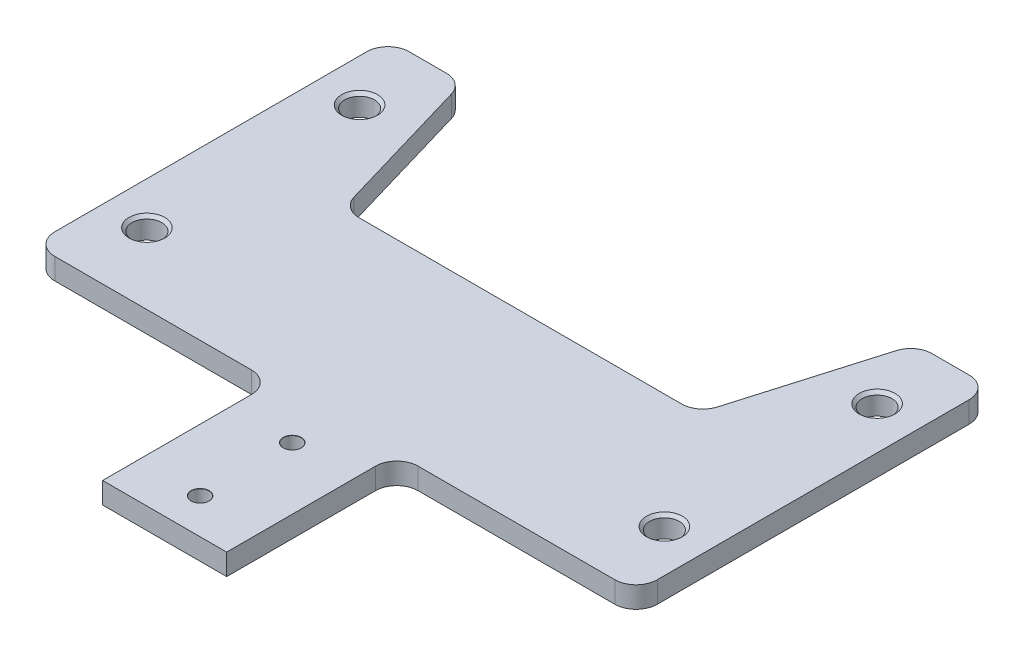
from build123d import *

# Parameters (mm, degrees)
BOSS_EXTRUDE1_DEPTH                  = 3
SKETCH10_W                           = 17.5
SKETCH10_H                           = 24
BOSS_EXTRUDE2_DEPTH                  = 3
F_2_5_2_5_DIAMETER_HOLE1_D           = 2.5
F_2_5_2_5_DIAMETER_HOLE1_DEPTH       = 6.35
F_2_5_2_5_DIAMETER_HOLE1_CSINK_D     = 2.55
F_2_5_2_5_DIAMETER_HOLE1_CSINK_ANGLE = 90
F_2_5_2_5_DIAMETER_HOLE1_TIP         = 0.751075774
M5X0_8_TAPPED_HOLE1_D                = 4.2
M5X0_8_TAPPED_HOLE1_DEPTH            = 12.4
M5X0_8_TAPPED_HOLE1_CSINK_D          = 5.05
M5X0_8_TAPPED_HOLE1_CSINK_ANGLE      = 90
M5X0_8_TAPPED_HOLE1_TIP              = 1.2618073
CUT_EXTRUDE3_DEPTH                   = 4
FILLET1_R                            = 3


with BuildPart() as part:
    # Sketch2 → Boss-Extrude1 (new body)
    with BuildSketch(Plane(origin=(0, 0, 0), x_dir=(1, 0, 0), z_dir=(0, 1, 0))):
        Polygon((42.5, 0), (42.5, 50), (22.5, 50), (8.75, 26.184301396), (-8.75, 26.184301396), (-22.5, 50), (-42.5, 50), (-42.5, 0), align=None)
    extrude(amount=BOSS_EXTRUDE1_DEPTH)

    # Sketch10 → Boss-Extrude2 (add)
    with BuildSketch(Plane(origin=(0, 3, 0), x_dir=(1, 0, 0), z_dir=(0, 1, 0))):
        with Locations((0, -12)):
            Rectangle(SKETCH10_W, SKETCH10_H)
    extrude(amount=-BOSS_EXTRUDE2_DEPTH)

    # Ø2.5 (2.5) Diameter Hole1
    with Locations(Plane(origin=(0, 3, 0), x_dir=(1, 0, 0), z_dir=(0, 1, 0))):
        with Locations((0, -19), (0, -6)):
            CounterSinkHole(F_2_5_2_5_DIAMETER_HOLE1_D / 2, F_2_5_2_5_DIAMETER_HOLE1_CSINK_D / 2, depth=F_2_5_2_5_DIAMETER_HOLE1_DEPTH, counter_sink_angle=F_2_5_2_5_DIAMETER_HOLE1_CSINK_ANGLE)
            with Locations((0, 0, -(F_2_5_2_5_DIAMETER_HOLE1_DEPTH + F_2_5_2_5_DIAMETER_HOLE1_TIP / 2))):  # 118° drill point
                Cone(0, F_2_5_2_5_DIAMETER_HOLE1_D / 2, F_2_5_2_5_DIAMETER_HOLE1_TIP, mode=Mode.SUBTRACT)

    # M5x0.8 Tapped Hole1
    with Locations(Plane(origin=(0, 3, 0), x_dir=(1, 0, 0), z_dir=(0, 1, 0))):
        with Locations((-36.5, 40), (36.5, 40), (-36.5, 10), (36.5, 10)):
            CounterSinkHole(M5X0_8_TAPPED_HOLE1_D / 2, M5X0_8_TAPPED_HOLE1_CSINK_D / 2, depth=M5X0_8_TAPPED_HOLE1_DEPTH, counter_sink_angle=M5X0_8_TAPPED_HOLE1_CSINK_ANGLE)
            with Locations((0, 0, -(M5X0_8_TAPPED_HOLE1_DEPTH + M5X0_8_TAPPED_HOLE1_TIP / 2))):  # 118° drill point
                Cone(0, M5X0_8_TAPPED_HOLE1_D / 2, M5X0_8_TAPPED_HOLE1_TIP, mode=Mode.SUBTRACT)

    # Sketch9 → Cut-Extrude3 (cut, through all)
    with BuildSketch(Plane.XZ):
        Polygon((-32, -50), (-25, -26.184301396), (25, -26.184301396), (32, -50), align=None)
    extrude(amount=-CUT_EXTRUDE3_DEPTH, mode=Mode.SUBTRACT)

    # Fillet1
    fillet1_edges = [part.edges().sort_by_distance(p)[0] for p in [
        (25, 1.5, -26.184301396),
        (-42.5, 1.5, 0),
        (-42.5, 1.5, -50),
        (42.5, 1.5, -50),
        (42.5, 1.5, 0),
        (-8.75, 1.5, 0),
        (8.75, 1.5, 0),
        (32, 1.5, -50),
        (-25, 1.5, -26.184301396),
        (-32, 1.5, -50),
    ]]
    fillet(fillet1_edges, radius=FILLET1_R)


solid = part.part
